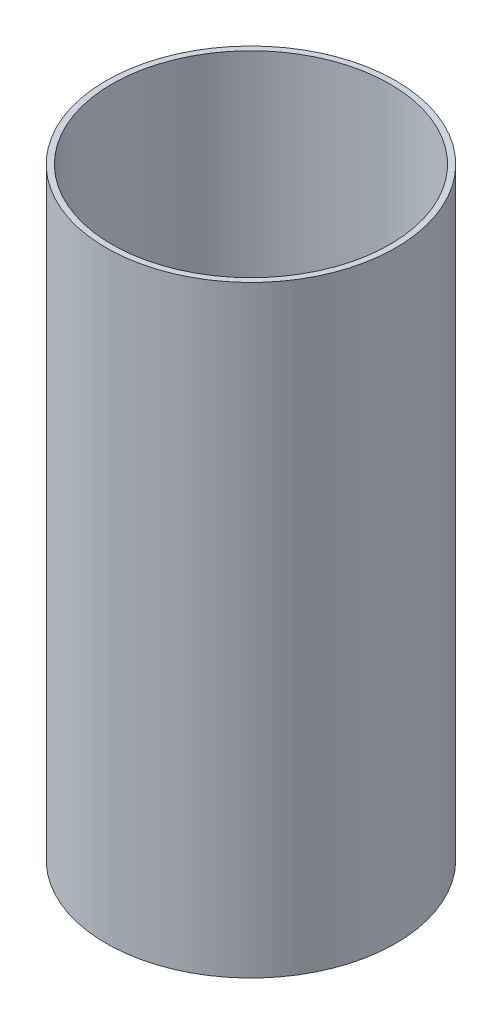
from build123d import *

# Parameters (mm, degrees)
SKETCH1_R      = 3.125
SKETCH1_R_2    = 3
EXTRUDE1_DEPTH = 13


with BuildPart() as part:
    # Sketch1 → Extrude1 (new body)
    with BuildSketch(Plane.XZ):
        with Locations((0, 24.99995)):
            Circle(SKETCH1_R)
        with Locations((0, 24.99995)):
            Circle(SKETCH1_R_2, mode=Mode.SUBTRACT)
    extrude(amount=-EXTRUDE1_DEPTH)


solid = part.part
